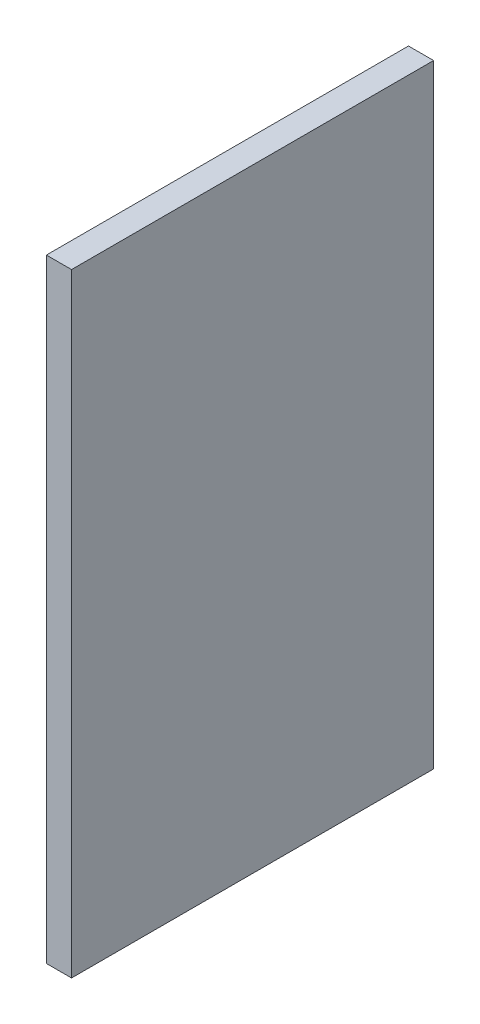
from build123d import *

# Parameters (mm, degrees)
SKETCH2_W           = 5
SKETCH2_H           = 122
BOSS_EXTRUDE1_DEPTH = 72


with BuildPart() as part:
    # Sketch2 → Boss-Extrude1 (new body)
    with BuildSketch(Plane.XY.offset(-331.8)):
        with Locations((-120.1, -159)):
            Rectangle(SKETCH2_W, SKETCH2_H)
    extrude(amount=BOSS_EXTRUDE1_DEPTH)


solid = part.part
